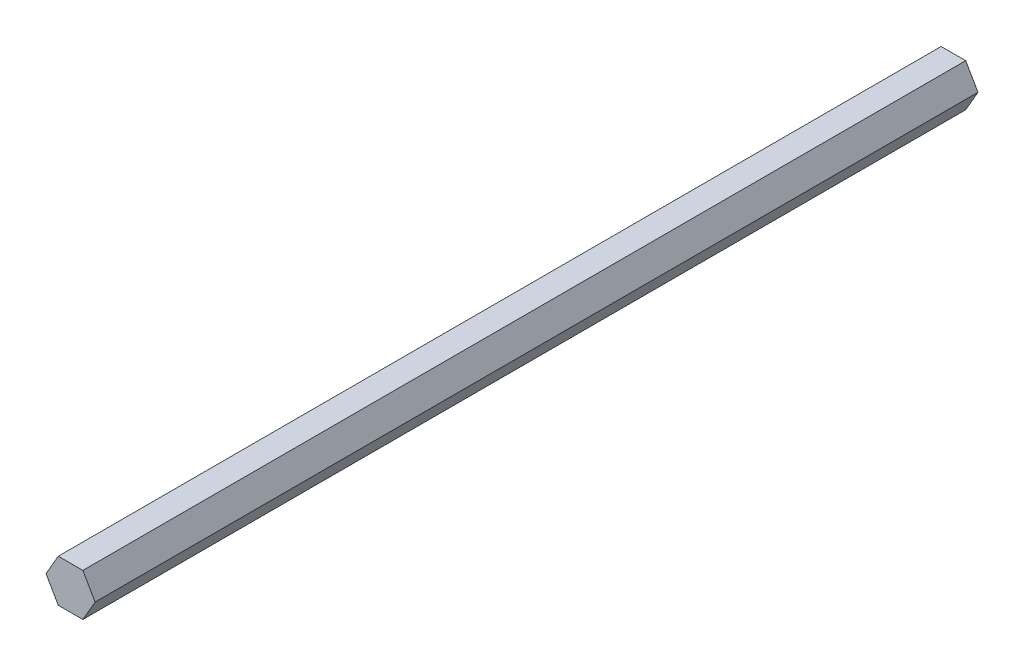
from build123d import *

# Parameters (mm, degrees)
BOSS_EXTRUDE1_DEPTH = 263.525


with BuildPart() as part:
    # Sketch1 → Boss-Extrude1 (new body)
    with BuildSketch(Plane.XY):
        Polygon((7.332348419, 0), (3.666174209, 6.35), (-3.666174209, 6.35), (-7.332348419, 0), (-3.666174209, -6.35), (3.666174209, -6.35), align=None)
    extrude(amount=BOSS_EXTRUDE1_DEPTH)


solid = part.part
